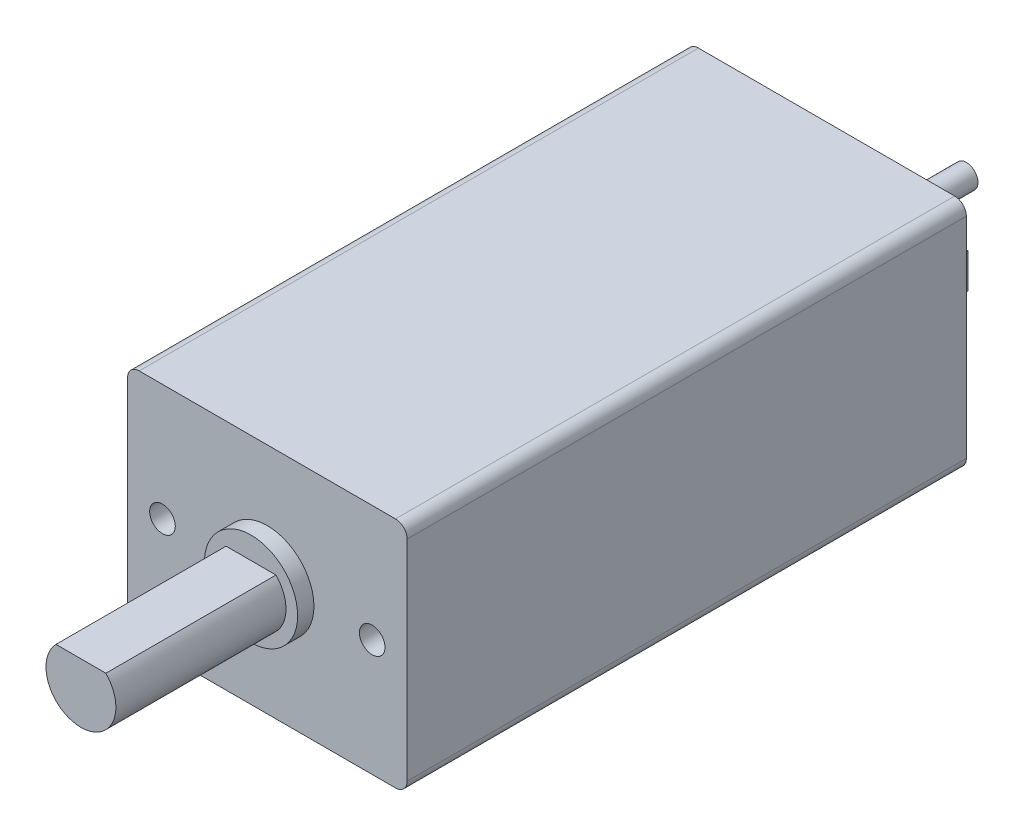
from build123d import *

# Parameters (mm, degrees)
TOP_W                                     = 12
TOP_H                                     = 10
PRECISION_MICRODRIVES_MODEL_212_109_DEPTH = 24
TOP_RING_2_R                              = 2
TOP_RING_DEPTH                            = 0.7
HOLE_WIZARD_M1_1_D                        = 1.1
HOLE_WIZARD_M1_1_DEPTH                    = 10
HOLE_WIZARD_M1_1_TIP                      = 0.337040433
HOLE_WIZARD_M1_2_D                        = 1.1
HOLE_WIZARD_M1_2_DEPTH                    = 10
HOLE_WIZARD_M1_2_TIP                      = 0.337040433
D_SHAFT_DEPTH                             = 8
VERRUNDUNG1_R                             = 0.5
SKIZZE12_R                                = 2.5
BOTTOM_DEPTH                              = 1.2
SKIZZE13_R                                = 0.5
BOLT_DEPTH                                = 6
SKIZZE14_W                                = 0.12
SKIZZE14_H                                = 1.5
FLAPS_DEPTH                               = 2.5
FLAP1_CUT_REACH                           = 11.56
SKIZZE15_R                                = 0.4
FLAP2_CUT_REACH                           = 11.56
SKIZZE16_R                                = 0.4


with BuildPart() as part:
    # top → Precision Microdrives Model 212-109 (new body)
    with BuildSketch(Plane.XY):
        Rectangle(TOP_W, TOP_H)
    extrude(amount=-PRECISION_MICRODRIVES_MODEL_212_109_DEPTH)

    # top ring 2 → top-ring (add)
    with BuildSketch(Plane.XY):
        Circle(TOP_RING_2_R)
    extrude(amount=TOP_RING_DEPTH)

    # Hole Wizard M1-1
    with Locations(Plane.XY):
        with Locations((-4.5, 0)):
            Hole(HOLE_WIZARD_M1_1_D / 2, depth=HOLE_WIZARD_M1_1_DEPTH)
            with Locations((0, 0, -(HOLE_WIZARD_M1_1_DEPTH + HOLE_WIZARD_M1_1_TIP / 2))):  # 117° drill point
                Cone(0, HOLE_WIZARD_M1_1_D / 2, HOLE_WIZARD_M1_1_TIP, mode=Mode.SUBTRACT)

    # Hole Wizard M1-2
    with Locations(Plane.XY):
        with Locations((4.5, 0)):
            Hole(HOLE_WIZARD_M1_2_D / 2, depth=HOLE_WIZARD_M1_2_DEPTH)
            with Locations((0, 0, -(HOLE_WIZARD_M1_2_DEPTH + HOLE_WIZARD_M1_2_TIP / 2))):  # 117° drill point
                Cone(0, HOLE_WIZARD_M1_2_D / 2, HOLE_WIZARD_M1_2_TIP, mode=Mode.SUBTRACT)

    # Skizze11 → D-Shaft (add)
    with BuildSketch(Plane.XY):
        with BuildLine():
            Line((-1.071214264, 1.05), (1.071214264, 1.05))
            ThreePointArc((1.071214264, 1.05), (0, -1.5), (-1.071214264, 1.05))
        make_face()
    extrude(amount=D_SHAFT_DEPTH)

    # Verrundung1
    verrundung1_edges = [part.edges().sort_by_distance(p)[0] for p in [
        (-6, 5, -12),
        (6, 5, -12),
        (6, -5, -12),
        (-6, -5, -12),
    ]]
    fillet(verrundung1_edges, radius=VERRUNDUNG1_R)

    # Skizze12 → bottom (add)
    with BuildSketch(Plane(origin=(0, 0, -24), x_dir=(-1, 0, 0), z_dir=(0, 0, -1))):
        Circle(SKIZZE12_R)
    extrude(amount=BOTTOM_DEPTH)

    # Skizze13 → bolt (add)
    with BuildSketch(Plane(origin=(0, 0, -24), x_dir=(-1, 0, 0), z_dir=(0, 0, -1))):
        Circle(SKIZZE13_R)
    extrude(amount=BOLT_DEPTH)

    # Skizze14 → flaps (add)
    with BuildSketch(Plane(origin=(0, 0, -24), x_dir=(-1, 0, 0), z_dir=(0, 0, -1))):
        with Locations((-3.5, 0)):
            Rectangle(SKIZZE14_W, SKIZZE14_H)
        with Locations((3.5, 0)):
            Rectangle(SKIZZE14_W, SKIZZE14_H)
    extrude(amount=FLAPS_DEPTH)

    # Skizze15 → flap1-cut (cut, up to next)
    with BuildSketch(Plane.ZY.offset(3.56), mode=Mode.PRIVATE) as flap1_cut_sk1:
        with Locations((-25.7, 0)):
            Circle(SKIZZE15_R)
    flap1_cut_tool1 = extrude(flap1_cut_sk1.sketch, amount=-FLAP1_CUT_REACH, mode=Mode.PRIVATE) & part.part
    add(flap1_cut_tool1.solids().sort_by_distance((-3.56, 0, -25.7))[0], mode=Mode.SUBTRACT)

    # Skizze16 → flap2-cut (cut, up to next)
    with BuildSketch(Plane(origin=(3.56, 0, 0), x_dir=(0, 0, -1), z_dir=(1, 0, 0)), mode=Mode.PRIVATE) as flap2_cut_sk1:
        with Locations((25.7, 0)):
            Circle(SKIZZE16_R)
    flap2_cut_tool1 = extrude(flap2_cut_sk1.sketch, amount=-FLAP2_CUT_REACH, mode=Mode.PRIVATE) & part.part
    add(flap2_cut_tool1.solids().sort_by_distance((3.56, 0, -25.7))[0], mode=Mode.SUBTRACT)


solid = part.part
